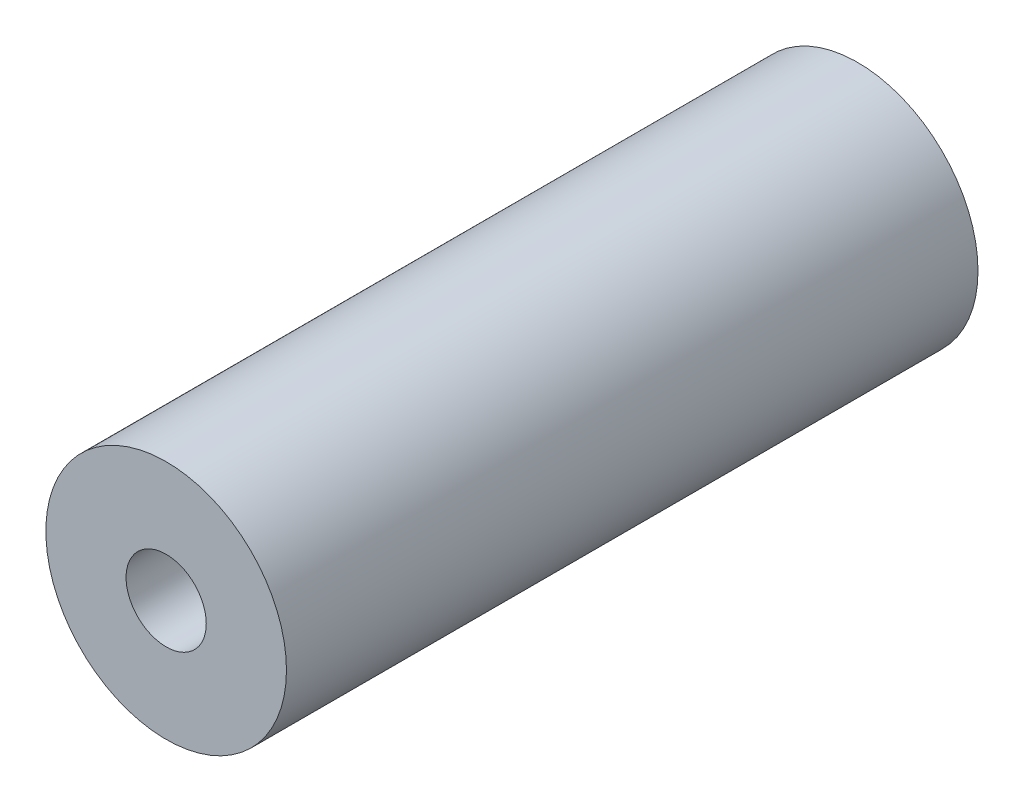
from build123d import *

# Parameters (mm, degrees)
SKETCH1_R           = 19.05
SKETCH1_R_2         = 6.35
BOSS_EXTRUDE1_DEPTH = 54.75


with BuildPart() as part:
    # Sketch1 → Boss-Extrude1 (new body, symmetric)
    with BuildSketch(Plane.XY):
        Circle(SKETCH1_R)
        Circle(SKETCH1_R_2, mode=Mode.SUBTRACT)
    extrude(amount=BOSS_EXTRUDE1_DEPTH, both=True)


solid = part.part
